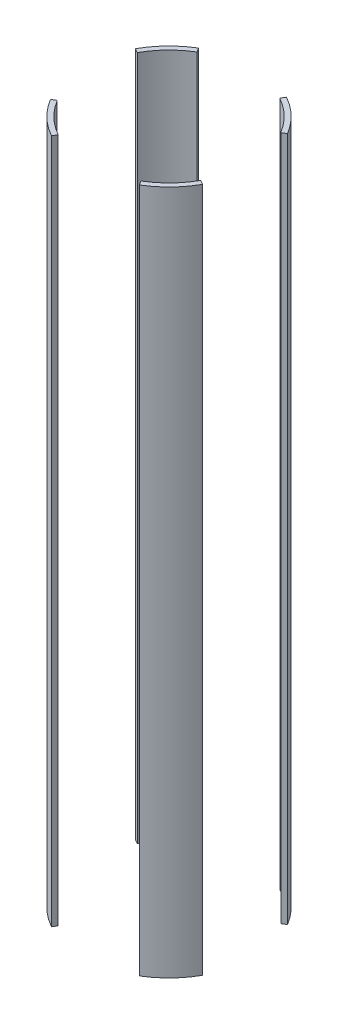
from build123d import *

# Parameters (mm, degrees)
SKETCH2_R               = 88.9
SKETCH2_R_2             = 83.82
BOSS_EXTRUDE1_DEPTH     = 352.425
CUT_EXTRUDE1_DEPTH      = 353.425
CUT_EXTRUDE1_DEPTH_BACK = 353.425


with BuildPart() as part:
    # Sketch2 → Boss-Extrude1 (new body, symmetric)
    with BuildSketch(Plane(origin=(0, 0, 0), x_dir=(1, 0, 0), z_dir=(0, 1, 0))):
        Circle(SKETCH2_R)
        Circle(SKETCH2_R_2, mode=Mode.SUBTRACT)
    extrude(amount=BOSS_EXTRUDE1_DEPTH, both=True)

    # Sketch3 → Cut-Extrude1 (cut, two sides)
    with BuildSketch(Plane(origin=(0, 0, 0), x_dir=(1, 0, 0), z_dir=(0, 1, 0))) as cut_extrude1_sk:
        Polygon((169.661755759, -94.300371224), (0, 0), (169.661755759, 101.677593364), align=None)
        Polygon((0, 0), (53.900027233, 96.974944394), (-58.116685864, 96.974944394), align=None)
        Polygon((-123.741299607, 68.777140945), (-123.741299607, -74.157652604), (0, 0), align=None)
        Polygon((-65.840936026, -118.45858783), (0, 0), (70.991745134, -118.45858783), align=None)
    extrude(amount=CUT_EXTRUDE1_DEPTH, mode=Mode.SUBTRACT)
    extrude(cut_extrude1_sk.sketch, amount=-CUT_EXTRUDE1_DEPTH_BACK, mode=Mode.SUBTRACT)


solid = part.part
